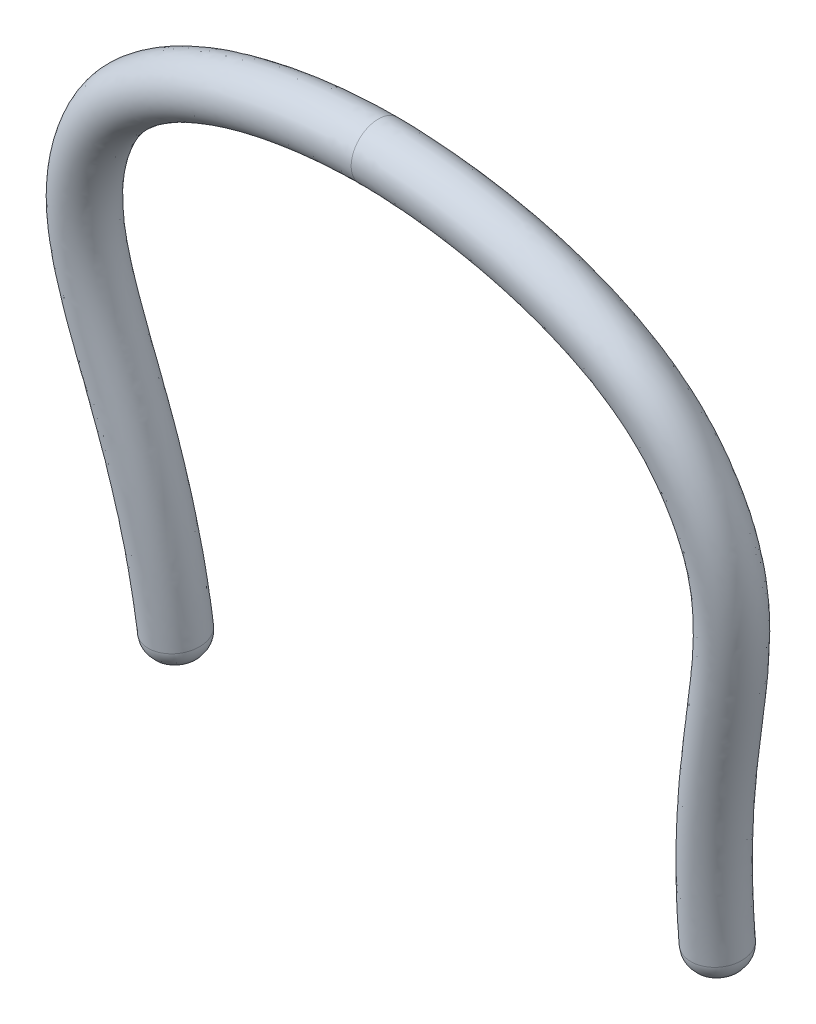
from build123d import *

# Parameters (mm, degrees)
SKETCH7_R = 12.5
FILLET1_R = 10


with BuildPart() as part:
    # Sweep1: sweep along a curve in space
    with BuildLine() as sweep1_path:
        add(Edge.make_bspline(
            [(125, -79.309135517, 0), (125, -63.494194466, 1.646486147), (125.850243288, -47.759193512, 3.316968563), (128.492829684, -24.284711788, 5.856374519), (129.600133396, -16.481092348, 6.708467843), (132.224711239, -0.912384817, 8.424093015), (133.743581414, 6.847504253, 9.287060856), (137.042302279, 22.295508168, 11.020413319), (138.826441328, 29.990286574, 11.891516071), (142.350283539, 45.387474994, 13.64991309), (144.092947643, 53.089264223, 14.537117579), (146.958547346, 68.621443766, 16.34203372), (148.064164203, 76.410819079, 17.255011451), (148.631739523, 88.149220703, 18.642811842), (148.638423458, 92.071864132, 19.108561952), (148.197351635, 99.941764451, 20.047016346), (147.742901852, 103.909493606, 20.522204013), (145.671794944, 115.546641535, 21.921757719), (143.3648701, 123.034090235, 22.8300341), (138.659923071, 133.901695935, 24.158209887), (136.869683177, 137.468915428, 24.595912908), (132.921594308, 144.273437546, 25.433768492), (130.754678239, 147.534936441, 25.836870702), (125.991361143, 153.74462153, 26.60674155), (123.386892727, 156.686929177, 26.972773745), (117.762658622, 162.268660438, 27.669069464), (114.747178596, 164.901229364, 27.998489879), (105.412544095, 172.19320559, 28.913098824), (98.72598455, 176.343215862, 29.436575119), (88.178338588, 181.773751558, 30.123661831), (84.560278541, 183.454942601, 30.336796722), (77.252321007, 186.537952444, 30.728214594), (73.561788125, 187.941793453, 30.906750818), (62.394058883, 191.791323905, 31.396898945), (54.82180226, 193.879053276, 31.663540612), (39.460063871, 197.236674246, 32.092901689), (31.670412884, 198.505926944, 32.255554216), (15.876503735, 200.236547481, 32.477433137), (7.948776105, 200.690864483, 32.535755702), (0, 200.690864483, 32.535755702)],
            knots=[0, 0, 0, 0, 0.125, 0.125, 0.1875, 0.1875, 0.25, 0.25, 0.3125, 0.3125, 0.375, 0.375, 0.4375, 0.4375, 0.46875, 0.46875, 0.5, 0.5, 0.5625, 0.5625, 0.59375, 0.59375, 0.625, 0.625, 0.65625, 0.65625, 0.6875, 0.6875, 0.75, 0.75, 0.78125, 0.78125, 0.8125, 0.8125, 0.875, 0.875, 0.9375, 0.9375, 1, 1, 1, 1], degree=3))
    # Sketch7 → Sweep1 (sweep)
    with BuildSketch(Plane(origin=(0, 0, 0), x_dir=(0, 0, -1), z_dir=(1, 0, 0))):
        with Locations((-32.535755702, 200.690864483)):
            Circle(SKETCH7_R)
    sweep1 = sweep(path=sweep1_path.line)

    # Mirror1: Sweep1 across plane
    add(sweep1.mirror(Plane(origin=(0, 200.690864483, 32.535755702), x_dir=(0, 0, 1), z_dir=(1, 0, 0))))

    # Fillet1
    fillet1_edges = [part.edges().sort_by_distance(p)[0] for p in [
        (-126.550463303, -80.593513189, 12.336792028),
        (126.550463303, -80.593513189, 12.336792028),
    ]]
    fillet(fillet1_edges, radius=FILLET1_R)


solid = part.part
